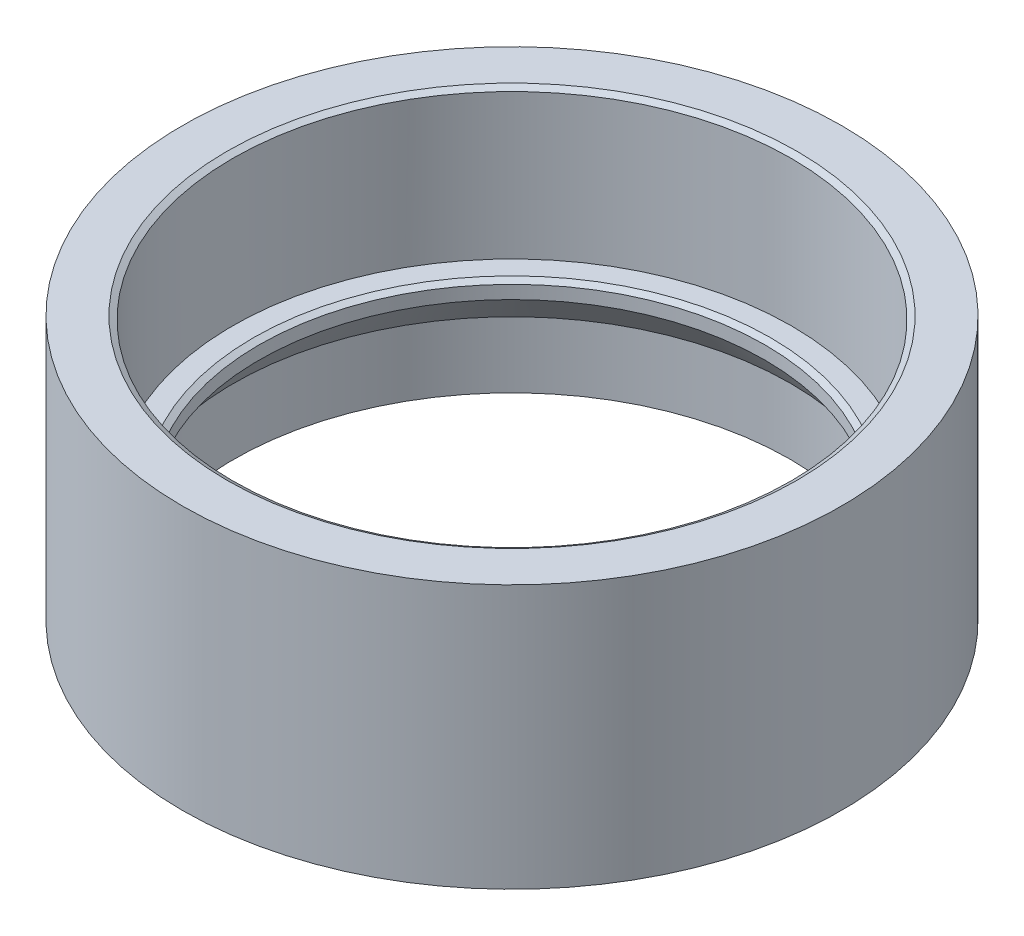
from build123d import *

# Parameters (mm, degrees)
CHAMFER2_SIZE         = 1
CHAMFER2_SIZE2        = 1.732050808
CHAMFER2_PART_2_SIZE  = 1
CHAMFER2_PART_2_SIZE2 = 1.732050808
FILLET1_R             = 1


with BuildPart() as part:
    # Sketch1 → Revolve1 (revolve)
    with BuildSketch(Plane.XY):
        Polygon((84.75, 80), (100, 80), (100, 0), (95, 0), (95, 5), (89.9, 5), (89.9, 0), (84.5, 0), (84.5, 20), (76.75, 29.998444487), (76.75, 34.998444487), (84.75, 34.998444487), align=None)
    revolve(axis=Axis((0, 0, 0), (0, 1, 0)))

    # Chamfer2
    chamfer2_edges = [part.edges().sort_by_distance(p)[0] for p in [
        (-84.75, 80, 0),
    ]]
    chamfer2_side = [part.faces().sort_by_distance(p)[0] for p in [
        (-84.75, 57.499222243, 0),
    ]]
    chamfer(chamfer2_edges, length=CHAMFER2_SIZE, length2=CHAMFER2_SIZE2, reference=chamfer2_side[0])

    # Chamfer2 part 2
    chamfer2_part_2_edges = [part.edges().sort_by_distance(p)[0] for p in [
        (-76.75, 34.998444487, 0),
    ]]
    chamfer2_part_2_side = [part.faces().sort_by_distance(p)[0] for p in [
        (-76.75, 32.498444487, 0),
    ]]
    chamfer(chamfer2_part_2_edges, length=CHAMFER2_PART_2_SIZE, length2=CHAMFER2_PART_2_SIZE2, reference=chamfer2_part_2_side[0])

    # Fillet1
    fillet1_edges = [part.edges().sort_by_distance(p)[0] for p in [
        (-95, 0, 0),
        (-89.9, 0, 0),
    ]]
    fillet(fillet1_edges, radius=FILLET1_R)


solid = part.part
